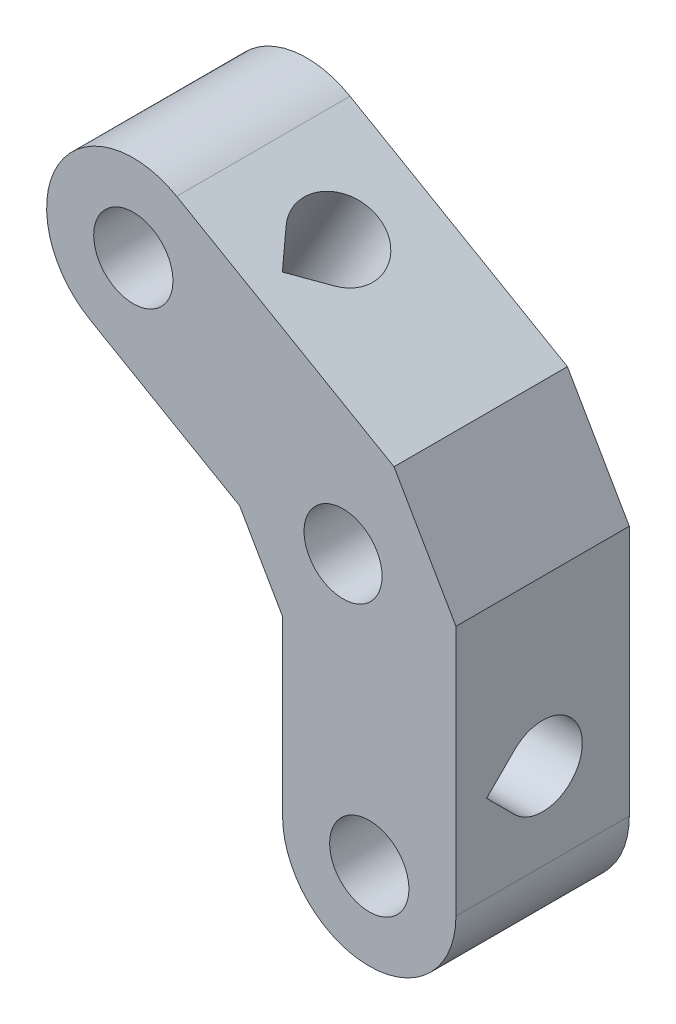
from build123d import *

# Parameters (mm, degrees)
BOSS_EXTRUDE1_DEPTH = 14
HOLE1_D             = 6.4
HOLE1_DEPTH         = 14
HOLE2_D             = 6.4
HOLE2_DEPTH         = 14
CUT_EXTRUDE1_DEPTH  = 27.088457268
CUT_EXTRUDE2_DEPTH  = 15
SKETCH8_R           = 3.15
CUT_EXTRUDE3_DEPTH  = 15


with BuildPart() as part:
    # Sketch1 → Boss-Extrude1 (new body)
    with BuildSketch(Plane.XY.offset(14)):
        with BuildLine():
            Line((7, 0), (7, 20.267949192))
            Line((7, 20.267949192), (2, 28.92820323))
            Line((2, 28.92820323), (-15.552558883, 39.062177826))
            ThreePointArc((-15.552558883, 39.062177826), (-25.11473671, 36.5), (-22.552558883, 26.937822174))
            Line((-22.552558883, 26.937822174), (-10.464101615, 19.958548116))
            Line((-10.464101615, 19.958548116), (-7, 13.958548116))
            Line((-7, 13.958548116), (-7, 0))
            ThreePointArc((-7, 0), (0, -7), (7, 0))
        make_face()
    extrude(amount=-BOSS_EXTRUDE1_DEPTH)

    # Hole1
    with Locations(Plane(origin=(0, 0, 0), x_dir=(-1, 0, 0), z_dir=(0, 0, -1))):
        with Locations((0, 0)):
            Hole(HOLE1_D / 2, depth=HOLE1_DEPTH)

    # Hole2
    with Locations(Plane(origin=(0, 0, 0), x_dir=(-1, 0, 0), z_dir=(0, 0, -1))):
        with Locations((19.0525, 32.999898011)):
            Hole(HOLE2_D / 2, depth=HOLE2_DEPTH)

    # Sketch2 → Cut-Extrude1 (cut, through all)
    with BuildSketch(Plane(origin=(6.026279442, 10.437822174, 0), x_dir=(0.866025404, -0.5, 0), z_dir=(-0.5, -0.866025404, 0))):
        with BuildLine():
            Line((-25.999898011, 11.5254834), (-28.262639711, 9.2627417))
            ThreePointArc((-28.262639711, 9.2627417), (-25.999898011, 3.8), (-23.737156311, 9.2627417))
            Line((-23.737156311, 9.2627417), (-25.999898011, 11.5254834))
        make_face()
    extrude(amount=-CUT_EXTRUDE1_DEPTH, mode=Mode.SUBTRACT)

    # Sketch3 → Cut-Extrude2 (cut, through all)
    with BuildSketch(Plane.ZY.offset(7)):
        with BuildLine():
            Line((9.2627417, 4.7372583), (11.5254834, 7))
            Line((11.5254834, 7), (9.2627417, 9.2627417))
            ThreePointArc((9.2627417, 9.2627417), (3.8, 7), (9.2627417, 4.7372583))
        make_face()
    extrude(amount=-CUT_EXTRUDE2_DEPTH, mode=Mode.SUBTRACT)

    # Sketch8 → Cut-Extrude3 (cut, through all)
    with BuildSketch(Plane.XY.offset(14)):
        with Locations((-2.116025404, 20.778312164)):
            Circle(SKETCH8_R)
    extrude(amount=-CUT_EXTRUDE3_DEPTH, mode=Mode.SUBTRACT)


solid = part.part
